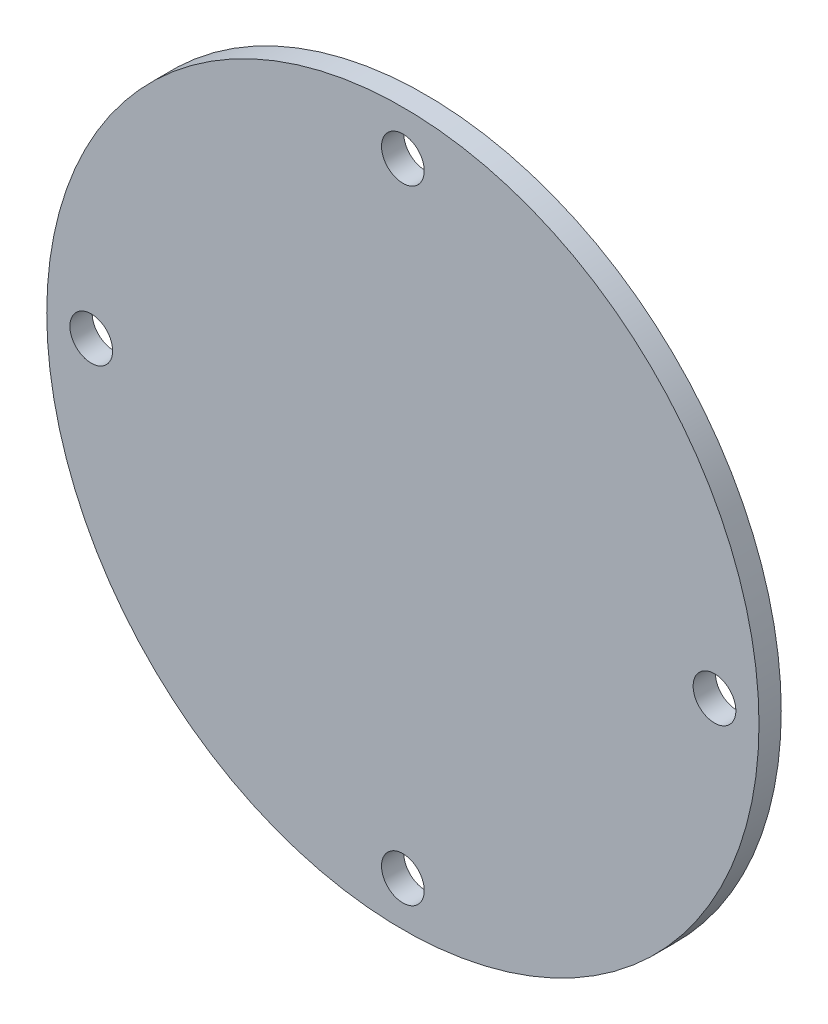
from build123d import *

# Parameters (mm, degrees)
SKETCH1_R           = 25.4
BOSS_EXTRUDE1_DEPTH = 1.5875
SKETCH2_R           = 1.524
CUT_EXTRUDE1_DEPTH  = 2.5875
CIRPATTERN1_COUNT   = 4


with BuildPart() as part:
    # Sketch1 → Boss-Extrude1 (new body)
    with BuildSketch(Plane.XY):
        Circle(SKETCH1_R)
    extrude(amount=BOSS_EXTRUDE1_DEPTH)

    # Sketch2 → Cut-Extrude1 (cut, through all)
    with BuildSketch(Plane.XY.offset(1.5875)):
        with Locations((0, 22.225)):
            Circle(SKETCH2_R)
    cut_extrude1 = extrude(amount=-CUT_EXTRUDE1_DEPTH, mode=Mode.SUBTRACT)

    # CirPattern1: Cut-Extrude1 ×4 about axis
    cirpattern1_axis = Axis((0, 0, 0), (0, 0, 1))
    for i in range(1, CIRPATTERN1_COUNT):
        add(cut_extrude1.rotate(cirpattern1_axis, i * 360 / CIRPATTERN1_COUNT), mode=Mode.SUBTRACT)


solid = part.part
